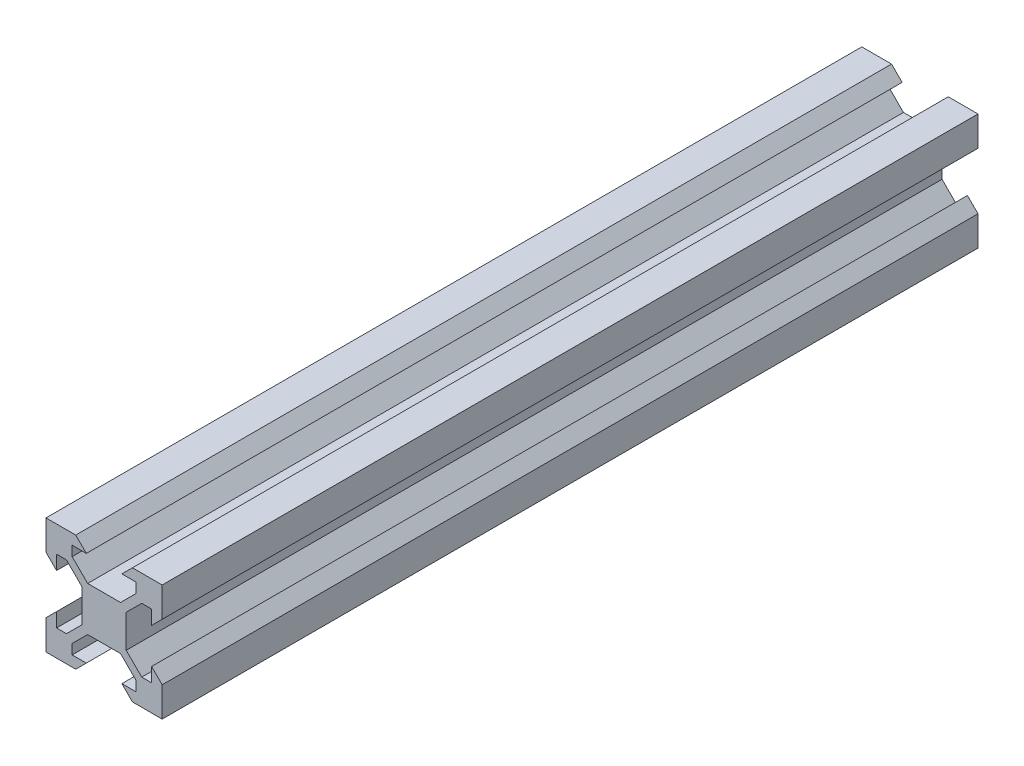
from build123d import *

# Parameters (mm, degrees)
SKETCH1_W           = 20
SKETCH1_H           = 20
BOSS_EXTRUDE1_DEPTH = 140.43
CUT_EXTRUDE1_DEPTH  = 141.43


with BuildPart() as part:
    # Sketch1 → Boss-Extrude1 (new body)
    with BuildSketch(Plane.XY):
        with Locations((10, 10)):
            Rectangle(SKETCH1_W, SKETCH1_H)
    extrude(amount=BOSS_EXTRUDE1_DEPTH)

    # Sketch2 → Cut-Extrude1 (cut, through all)
    with BuildSketch(Plane.XY.offset(140.43)):
        Polygon((4.5, 18.18), (6.94, 18.18), (5.12, 20), (14.88, 20), (13.06, 18.18), (15.5, 18.18), (15.5, 16.475807358), (12.834192642, 13.81), (7.165807358, 13.81), (4.5, 16.475807358), align=None)
        Polygon((14.88, 0), (13.06, 1.82), (15.5, 1.82), (15.5, 3.524192642), (12.834192642, 6.19), (7.165807358, 6.19), (4.5, 3.524192642), (4.5, 1.82), (6.94, 1.82), (5.12, 0), align=None)
        Polygon((1.82, 4.5), (1.82, 6.94), (0, 5.12), (0, 14.88), (1.82, 13.06), (1.82, 15.5), (3.524192642, 15.5), (6.19, 12.834192642), (6.19, 7.165807358), (3.524192642, 4.5), align=None)
        Polygon((20, 14.88), (18.18, 13.06), (18.18, 15.5), (16.475807358, 15.5), (13.81, 12.834192642), (13.81, 7.165807358), (16.475807358, 4.5), (18.18, 4.5), (18.18, 6.94), (20, 5.12), align=None)
    extrude(amount=-CUT_EXTRUDE1_DEPTH, mode=Mode.SUBTRACT)


solid = part.part
